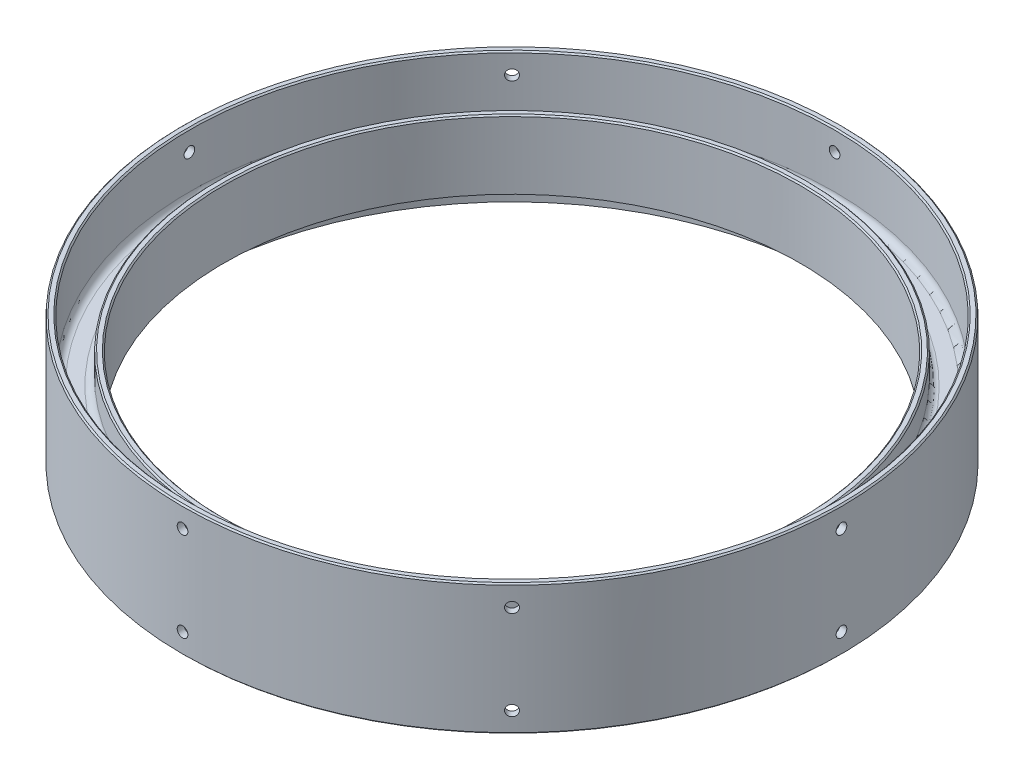
from build123d import *

# Parameters (mm, degrees)
FILLET1_R                             = 3.175
F_10_0_1935_DIAMETER_HOLE1_AT_2_COUNT = 2
F_10_0_1935_DIAMETER_HOLE1_AT_2_PITCH = 41.275
CIRPATTERN7_COUNT                     = 8
CHAMFER1_SIZE                         = 0.635


with BuildPart() as part:
    # Sketch1 → Revolve1 (revolve)
    with BuildSketch(Plane.XY):
        Polygon((133.35, 15.875), (133.35, -15.875), (136.525, -15.875), (136.525, -1.5875), (149.225, -1.5875), (149.225, -30.1625), (152.4, -30.1625), (152.4, 30.1625), (149.225, 30.1625), (149.225, 1.5875), (136.525, 1.5875), (136.525, 15.875), align=None)
    revolve(axis=Axis((0, 44.466373451, 0), (0, -1, 0)))

    # Fillet1
    fillet1_edges = [part.edges().sort_by_distance(p)[0] for p in [
        (-149.225, -1.5875, 0),
        (-136.525, -1.5875, 0),
        (-136.525, 1.5875, 0),
        (-149.225, 1.5875, 0),
    ]]
    fillet(fillet1_edges, radius=FILLET1_R)

    # Sketch9 → #10 (0.1935) Diameter Hole1 (revolve, cut)
    with BuildSketch(Plane(origin=(152.4, 20.6375, 0), x_dir=(0, 0, -1), z_dir=(0, 1, 0))):
        Polygon((0, 0), (0, 26.876584928), (2.45745, 25.4), (2.45745, 0), align=None)
    f_10_0_1935_diameter_hole1 = revolve(axis=Axis((158.75, 20.6375, 0), (-1, 0, 0)), mode=Mode.SUBTRACT)

    # #10 (0.1935) Diameter Hole1 at 2: #10 (0.1935) Diameter Hole1 ×2
    with Locations(*[(0, -i * F_10_0_1935_DIAMETER_HOLE1_AT_2_PITCH, 0) for i in range(1, F_10_0_1935_DIAMETER_HOLE1_AT_2_COUNT)]):
        add(f_10_0_1935_diameter_hole1, mode=Mode.SUBTRACT)

    # CirPattern7: #10 (0.1935) Diameter Hole1 ×8 about axis
    cirpattern7_axis = Axis((0, 30.1625, 0), (0, 1, 0))
    for i in range(1, CIRPATTERN7_COUNT):
        add(f_10_0_1935_diameter_hole1.rotate(cirpattern7_axis, i * 360 / CIRPATTERN7_COUNT), mode=Mode.SUBTRACT)

    # CirPattern7 copy 1 sketch → CirPattern7 copy 1 (revolve, cut)
    with BuildSketch(Plane(origin=(107.763073453, -20.6375, -107.763073453), x_dir=(-0.707106781, 0, -0.707106781), z_dir=(0, 1, 0))):
        Polygon((0, 0), (0, 26.876584928), (2.45745, 25.4), (2.45745, 0), align=None)
    revolve(axis=Axis((112.253201513, -20.6375, -112.253201513), (-0.707106781, 0, 0.707106781)), mode=Mode.SUBTRACT)

    # CirPattern7 copy 2 sketch → CirPattern7 copy 2 (revolve, cut)
    with BuildSketch(Plane(origin=(0, -20.6375, -152.4), x_dir=(-1, 0, 0), z_dir=(0, 1, 0))):
        Polygon((0, 0), (0, 26.876584928), (2.45745, 25.4), (2.45745, 0), align=None)
    revolve(axis=Axis((0, -20.6375, -158.75), (0, 0, 1)), mode=Mode.SUBTRACT)

    # CirPattern7 copy 3 sketch → CirPattern7 copy 3 (revolve, cut)
    with BuildSketch(Plane(origin=(-107.763073453, -20.6375, -107.763073453), x_dir=(-0.707106781, 0, 0.707106781), z_dir=(0, 1, 0))):
        Polygon((0, 0), (0, 26.876584928), (2.45745, 25.4), (2.45745, 0), align=None)
    revolve(axis=Axis((-112.253201513, -20.6375, -112.253201513), (0.707106781, 0, 0.707106781)), mode=Mode.SUBTRACT)

    # CirPattern7 copy 4 sketch → CirPattern7 copy 4 (revolve, cut)
    with BuildSketch(Plane(origin=(-152.4, -20.6375, 0), x_dir=(0, 0, 1), z_dir=(0, 1, 0))):
        Polygon((0, 0), (0, 26.876584928), (2.45745, 25.4), (2.45745, 0), align=None)
    revolve(axis=Axis((-158.75, -20.6375, 0), (1, 0, 0)), mode=Mode.SUBTRACT)

    # CirPattern7 copy 5 sketch → CirPattern7 copy 5 (revolve, cut)
    with BuildSketch(Plane(origin=(-107.763073453, -20.6375, 107.763073453), x_dir=(0.707106781, 0, 0.707106781), z_dir=(0, 1, 0))):
        Polygon((0, 0), (0, 26.876584928), (2.45745, 25.4), (2.45745, 0), align=None)
    revolve(axis=Axis((-112.253201513, -20.6375, 112.253201513), (0.707106781, 0, -0.707106781)), mode=Mode.SUBTRACT)

    # CirPattern7 copy 6 sketch → CirPattern7 copy 6 (revolve, cut)
    with BuildSketch(Plane(origin=(0, -20.6375, 152.4), x_dir=(1, 0, 0), z_dir=(0, 1, 0))):
        Polygon((0, 0), (0, 26.876584928), (2.45745, 25.4), (2.45745, 0), align=None)
    revolve(axis=Axis((0, -20.6375, 158.75), (0, 0, -1)), mode=Mode.SUBTRACT)

    # CirPattern7 copy 7 sketch → CirPattern7 copy 7 (revolve, cut)
    with BuildSketch(Plane(origin=(107.763073453, -20.6375, 107.763073453), x_dir=(0.707106781, 0, -0.707106781), z_dir=(0, 1, 0))):
        Polygon((0, 0), (0, 26.876584928), (2.45745, 25.4), (2.45745, 0), align=None)
    revolve(axis=Axis((112.253201513, -20.6375, 112.253201513), (-0.707106781, 0, -0.707106781)), mode=Mode.SUBTRACT)

    # Chamfer1
    chamfer1_edges = [part.edges().sort_by_distance(p)[0] for p in [
        (-152.4, 30.1625, 0),
        (-152.4, -30.1625, 0),
        (-133.35, 15.875, 0),
        (-136.525, 15.875, 0),
        (-149.225, 30.1625, 0),
    ]]
    chamfer(chamfer1_edges, length=CHAMFER1_SIZE)


solid = part.part
